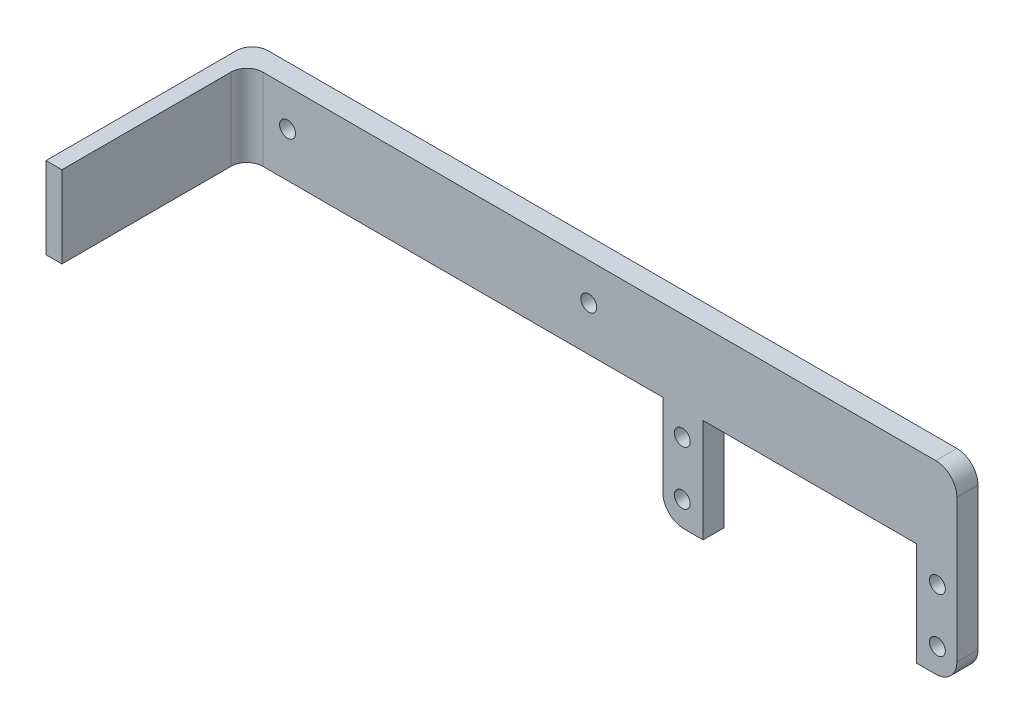
from build123d import *

# Parameters (mm, degrees)
BOSS_EXTRUDE2_DEPTH = 4
FILLET1_R           = 4
SKETCH6_R           = 1.5
CUT_EXTRUDE1_DEPTH  = 4
SKETCH3_R           = 1.5
CUT_EXTRUDE2_DEPTH  = 4
SKETCH7_W           = 3.00651588
SKETCH7_H           = 15.442
BOSS_EXTRUDE3_DEPTH = 35
FILLET2_R           = 3
FILLET3_R           = 3


with BuildPart() as part:
    # Sketch2 → Boss-Extrude2 (new body)
    with BuildSketch(Plane.XY):
        Polygon((-67.081093968, -2.634474623), (-67.081093968, 16.923525377), (-26.695093968, 16.923525377), (-26.695093968, -2.634474623), (-19.075093968, -2.634474623), (-19.075093968, 32.365525377), (-67.081093968, 32.365525377), (-74.701093968, 32.365525377), (-156.39106061, 32.365525377), (-156.39106061, 16.923525377), (-74.701093968, 16.923525377), (-74.701093968, -2.634474623), align=None)
    extrude(amount=BOSS_EXTRUDE2_DEPTH)

    # Fillet1
    fillet1_edges = [part.edges().sort_by_distance(p)[0] for p in [
        (-19.075093968, 32.365525377, 2),
        (-19.075093968, -2.634474623, 2),
        (-74.701093968, -2.634474623, 2),
    ]]
    fillet(fillet1_edges, radius=FILLET1_R)

    # Sketch6 → Cut-Extrude1 (cut)
    with BuildSketch(Plane.XY.offset(4)):
        with Locations((-71.018093968, 12.224525377)):
            Circle(SKETCH6_R)
        with Locations((-22.758093968, 12.224525377)):
            Circle(SKETCH6_R)
        with Locations((-22.758093968, 2.064525377)):
            Circle(SKETCH6_R)
        with Locations((-71.018093968, 2.064525377)):
            Circle(SKETCH6_R)
    extrude(amount=-CUT_EXTRUDE1_DEPTH, mode=Mode.SUBTRACT)

    # Sketch3 → Cut-Extrude2 (cut)
    with BuildSketch(Plane.XY.offset(4)):
        with Locations((-145.701093968, 25.365525377)):
            Circle(SKETCH3_R)
        with Locations((-88.701093968, 25.365525377)):
            Circle(SKETCH3_R)
    extrude(amount=-CUT_EXTRUDE2_DEPTH, mode=Mode.SUBTRACT)

    # Sketch7 → Boss-Extrude3 (add)
    with BuildSketch(Plane.XY.offset(4)):
        with Locations((-154.88780267, 24.644525377)):
            Rectangle(SKETCH7_W, SKETCH7_H)
    extrude(amount=BOSS_EXTRUDE3_DEPTH)

    # Fillet2
    fillet2_edges = [part.edges().sort_by_distance(p)[0] for p in [
        (-153.38454473, 24.644525377, 4),
    ]]
    fillet(fillet2_edges, radius=FILLET2_R)

    # Fillet3
    fillet3_edges = [part.edges().sort_by_distance(p)[0] for p in [
        (-156.39106061, 24.644525377, 0),
    ]]
    fillet(fillet3_edges, radius=FILLET3_R)


solid = part.part
